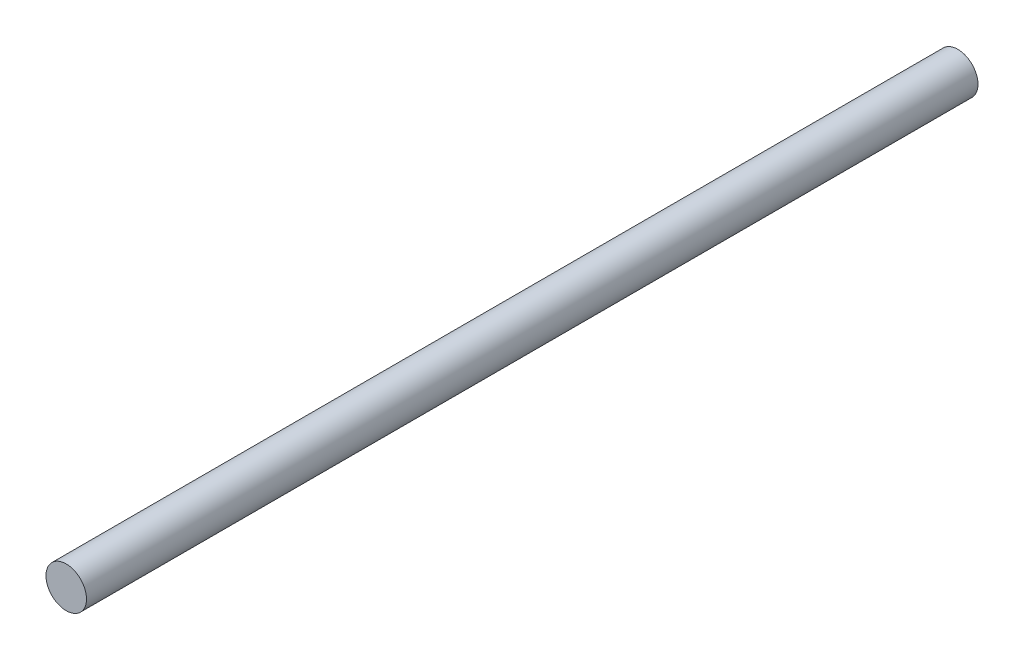
from build123d import *

# Parameters (mm, degrees)
ESQUISSE1_R        = 0.5
BOSS_EXTRU_1_DEPTH = 22


with BuildPart() as part:
    # Esquisse1 → Boss.-Extru.1 (new body)
    with BuildSketch(Plane.XY):
        Circle(ESQUISSE1_R)
    extrude(amount=BOSS_EXTRU_1_DEPTH)


solid = part.part
